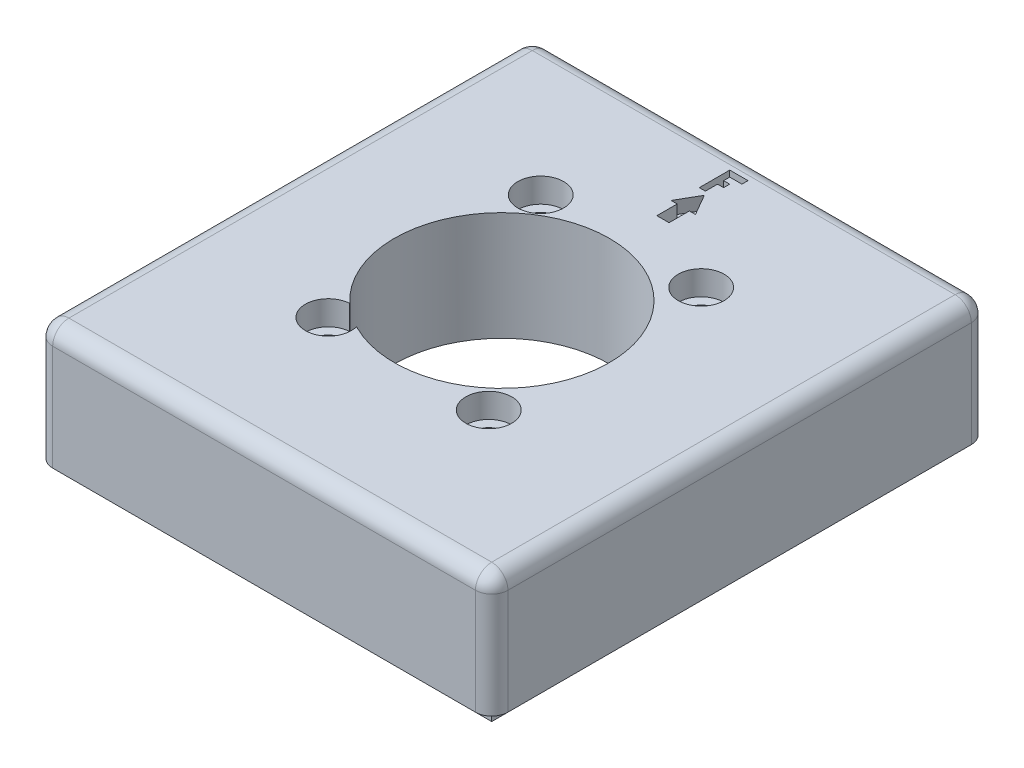
from build123d import *

# Parameters (mm, degrees)
SKETCH1_W           = 56.05
SKETCH1_H           = 61.05
SKETCH1_W_2         = 50.05
SKETCH1_H_2         = 55.05
SKETCH1_W_3         = 44.05
SKETCH1_H_3         = 49.05
BOSS_EXTRUDE1_DEPTH = 3
SKETCH1_3_W         = 56.05
SKETCH1_3_H         = 61.05
SKETCH1_3_W_2       = 50.05
SKETCH1_3_H_2       = 55.05
SKETCH1_3_W_3       = 44.05
SKETCH1_3_H_3       = 49.05
BOSS_EXTRUDE2_DEPTH = 15
SKETCH1_4_W         = 50.05
SKETCH1_4_H         = 55.05
SKETCH1_4_W_2       = 44.05
SKETCH1_4_H_2       = 49.05
BOSS_EXTRUDE3_DEPTH = 18
FILLET1_R           = 2
SKETCH2_R           = 13.25
CUT_EXTRUDE1_DEPTH  = 19
SKETCH2_9_R         = 2.825
SKETCH2_9_R_2       = 1.6
SKETCH2_9_R_3       = 13.25
CUT_EXTRUDE2_DEPTH  = 3
CUT_EXTRUDE3_START  = -3
SKETCH2_10_R        = 1.6
SKETCH2_10_W        = 13
SKETCH2_10_H        = 10.44
SKETCH2_10_H_2      = 1
SKETCH2_10_W_2      = 0.1
SKETCH2_10_H_3      = 11.1
CUT_EXTRUDE3_DEPTH  = 16
SKETCH5_W           = 44.05
SKETCH5_H           = 49.05
CUT_EXTRUDE4_DEPTH  = 1.6
SKETCH2_11_W        = 2.25
SKETCH2_11_H        = 0.408076211
SKETCH2_11_W_2      = 1.5
SKETCH2_11_H_2      = 2.5
CUT_EXTRUDE5_DEPTH  = 1.6


with BuildPart() as part:
    # Sketch1 → Boss-Extrude1 (new body)
    with BuildSketch(Plane(origin=(0, 0, 0), x_dir=(1, 0, 0), z_dir=(0, 1, 0))):
        Rectangle(SKETCH1_W, SKETCH1_H)
        Rectangle(SKETCH1_W_2, SKETCH1_H_2, mode=Mode.SUBTRACT)
        Rectangle(SKETCH1_W_2, SKETCH1_H_2)
        Rectangle(SKETCH1_W_3, SKETCH1_H_3, mode=Mode.SUBTRACT)
        Rectangle(SKETCH1_W_3, SKETCH1_H_3)
    extrude(amount=-BOSS_EXTRUDE1_DEPTH)

    # Sketch1_3 → Boss-Extrude2 (add)
    with BuildSketch(Plane(origin=(0, 0, 0), x_dir=(1, 0, 0), z_dir=(0, 1, 0))):
        Rectangle(SKETCH1_3_W, SKETCH1_3_H)
        Rectangle(SKETCH1_3_W_2, SKETCH1_3_H_2, mode=Mode.SUBTRACT)
        Rectangle(SKETCH1_3_W_2, SKETCH1_3_H_2)
        Rectangle(SKETCH1_3_W_3, SKETCH1_3_H_3, mode=Mode.SUBTRACT)
        Rectangle(SKETCH1_3_W_3, SKETCH1_3_H_3)
    extrude(amount=-BOSS_EXTRUDE2_DEPTH)

    # Sketch1_4 → Boss-Extrude3 (add)
    with BuildSketch(Plane(origin=(0, 0, 0), x_dir=(1, 0, 0), z_dir=(0, 1, 0))):
        Rectangle(SKETCH1_4_W, SKETCH1_4_H)
        Rectangle(SKETCH1_4_W_2, SKETCH1_4_H_2, mode=Mode.SUBTRACT)
    extrude(amount=-BOSS_EXTRUDE3_DEPTH)

    # Fillet1
    fillet1_edges = [part.edges().sort_by_distance(p)[0] for p in [
        (-28.025, 0, 0),
        (0, 0, -30.525),
        (28.025, 0, 0),
        (0, 0, 30.525),
        (-28.025, -7.5, 30.525),
        (-28.025, -7.5, -30.525),
        (28.025, -7.5, -30.525),
        (28.025, -7.5, 30.525),
    ]]
    fillet(fillet1_edges, radius=FILLET1_R)

    # Sketch2 → Cut-Extrude1 (cut, through all)
    with BuildSketch(Plane(origin=(0, 0, 0), x_dir=(1, 0, 0), z_dir=(0, 1, 0))):
        with Locations(Location((-1.25, 0, 0), (0, 0, 270))):  # turned: the seam where the file's is
            Circle(SKETCH2_R)
    extrude(amount=-CUT_EXTRUDE1_DEPTH, mode=Mode.SUBTRACT)

    # Sketch2_9 → Cut-Extrude2 (cut)
    with BuildSketch(Plane(origin=(0, 0, 0), x_dir=(1, 0, 0), z_dir=(0, 1, 0))):
        with Locations(Location((-10.125, 13.665, 0), (0, 0, 270))):  # turned: the seam where the file's is
            Circle(SKETCH2_9_R)
        with Locations((-10.125, 13.665)):
            Circle(SKETCH2_9_R_2, mode=Mode.SUBTRACT)
        with Locations(Location((9.625, 13.665, 0), (0, 0, 270))):  # turned: the seam where the file's is
            Circle(SKETCH2_9_R)
        with Locations((9.625, 13.665)):
            Circle(SKETCH2_9_R_2, mode=Mode.SUBTRACT)
        with Locations(Location((9.625, -12.485, 0), (0, 0, 270))):  # turned: the seam where the file's is
            Circle(SKETCH2_9_R)
        with Locations((9.625, -12.485)):
            Circle(SKETCH2_9_R_2, mode=Mode.SUBTRACT)
        with Locations(Location((-1.25, 0, 0), (0, 0, 270))):  # turned: the seam where the file's is
            Circle(SKETCH2_9_R_3)
        with Locations((-10.125, -12.485)):
            Circle(SKETCH2_9_R)
        with Locations((-10.125, -12.485)):
            Circle(SKETCH2_9_R_2, mode=Mode.SUBTRACT)
        with Locations(Location((-1.25, 0, 0), (0, 0, 270))):  # turned: the seam where the file's is
            Circle(SKETCH2_9_R_3)
        with Locations((-10.125, -12.485)):
            Circle(SKETCH2_9_R)
        with Locations((-10.125, 13.665)):
            Circle(SKETCH2_9_R_2)
        with Locations((9.625, 13.665)):
            Circle(SKETCH2_9_R_2)
        with Locations((9.625, -12.485)):
            Circle(SKETCH2_9_R_2)
        with Locations((-10.125, -12.485)):
            Circle(SKETCH2_9_R_2)
    extrude(amount=-CUT_EXTRUDE2_DEPTH, mode=Mode.SUBTRACT)

    # Sketch2_10 → Cut-Extrude3 (cut, through all)
    with BuildSketch(Plane(origin=(0, 0, 0), x_dir=(1, 0, 0), z_dir=(0, 1, 0)).offset(CUT_EXTRUDE3_START)):
        with Locations(Location((-10.125, 13.665, 0), (0, 0, 270))):  # turned: the seam where the file's is
            Circle(SKETCH2_10_R)
        with Locations(Location((9.625, 13.665, 0), (0, 0, 270))):  # turned: the seam where the file's is
            Circle(SKETCH2_10_R)
        with Locations(Location((9.625, -12.485, 0), (0, 0, 270))):  # turned: the seam where the file's is
            Circle(SKETCH2_10_R)
        with Locations(Location((-10.125, -12.485, 0), (0, 0, 270))):  # turned: the seam where the file's is
            Circle(SKETCH2_10_R)
        with BuildLine():
            Line((-7.125, -17.085), (5.875, -17.085))
            Line((5.875, -17.085), (5.875, -11.171252168))
            ThreePointArc((5.875, -11.171252168), (-0.532432127, -13.230555406), (-7.125, -11.876315717))
            Line((-7.125, -11.876315717), (-7.125, -17.085))
        make_face()
        with Locations((-0.625, -22.305)):
            Rectangle(SKETCH2_10_W, SKETCH2_10_H)
        with Locations((-0.625, -28.025)):
            Rectangle(SKETCH2_10_W, SKETCH2_10_H_2)
        with BuildLine():
            Line((10.781624994, -5.55), (13.25, -5.55))
            Line((13.25, -5.55), (13.25, 5.55))
            Line((13.25, 5.55), (10.781624994, 5.55))
            ThreePointArc((10.781624994, 5.55), (11.691822344, 2.841079797), (12, 0))
            ThreePointArc((12, 0), (11.691822344, -2.841079797), (10.781624994, -5.55))
        make_face()
        with Locations((13.3, 0)):
            Rectangle(SKETCH2_10_W_2, SKETCH2_10_H_3)
    extrude(amount=-CUT_EXTRUDE3_DEPTH, mode=Mode.SUBTRACT)

    # Sketch5 → Cut-Extrude4 (cut)
    with BuildSketch(Plane.XZ.offset(15)):
        Rectangle(SKETCH5_W, SKETCH5_H)
    extrude(amount=-CUT_EXTRUDE4_DEPTH, mode=Mode.SUBTRACT)

    # Sketch2_11 → Cut-Extrude5 (cut)
    with BuildSketch(Plane(origin=(0, 0, 0), x_dir=(1, 0, 0), z_dir=(0, 1, 0))):
        Polygon((-0.375, 27.183076211), (1.125, 27.183076211), (1.125, 27.525), (-1.125, 27.525), (-1.125, 24.183076211), (-0.375, 24.183076211), (-0.375, 25.683076211), (0.375, 25.683076211), (0.375, 26.433076211), (-0.375, 26.433076211), align=None)
        with Locations((0, 27.729038106)):
            Rectangle(SKETCH2_11_W, SKETCH2_11_H)
        Polygon((-1.5, 21.085), (-0.75, 21.085), (0.75, 21.085), (1.5, 21.085), (0, 23.683076211), align=None)
        with Locations((0, 19.835)):
            Rectangle(SKETCH2_11_W_2, SKETCH2_11_H_2)
    extrude(amount=-CUT_EXTRUDE5_DEPTH, mode=Mode.SUBTRACT)


solid = part.part
